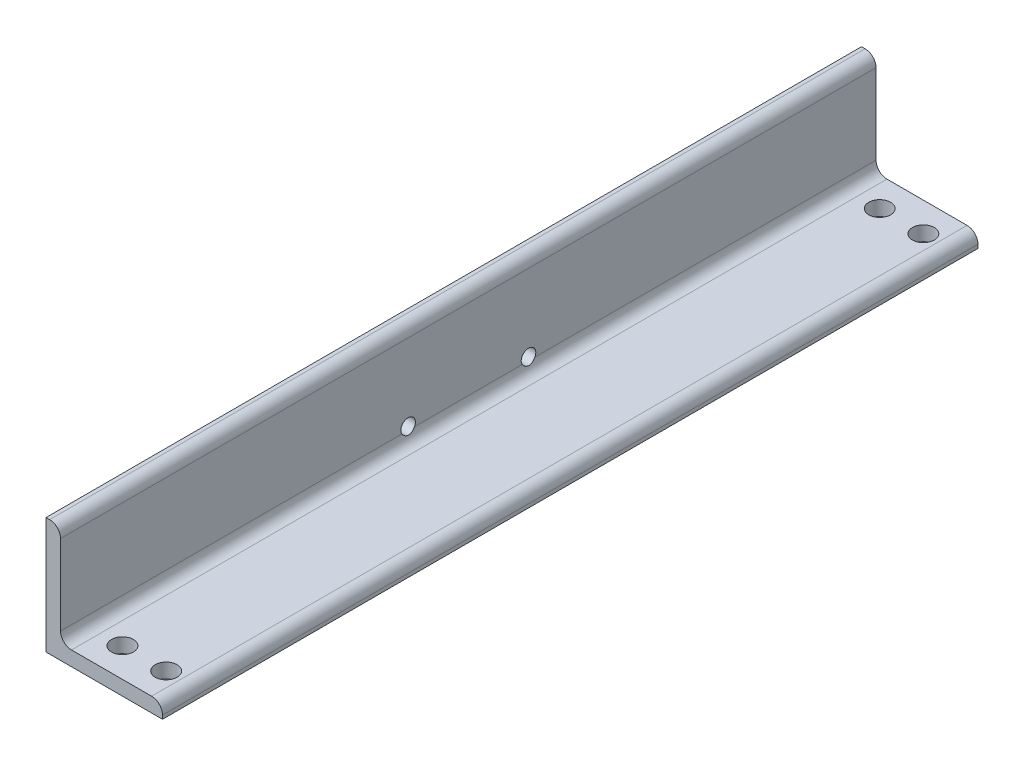
from build123d import *

# Parameters (mm, degrees)
BOSS_EXTRUDE1_DEPTH = 355.6
CUT_EXTRUDE1_REACH  = 14.7
SKETCH3_R           = 9.525
CUT_EXTRUDE2_REACH  = 103.6
SKETCH4_R           = 6.35


with BuildPart() as part:
    # Sketch1 → Boss-Extrude1 (new body, symmetric)
    with BuildSketch(Plane.XY):
        with BuildLine():
            Line((0, 0), (0, 101.6))
            Line((0, 101.6), (3.18008, 101.6))
            ThreePointArc((3.18008, 101.6), (9.911679988, 98.811679988), (12.7, 92.08008))
            Line((12.7, 92.08008), (12.7, 22.225))
            ThreePointArc((12.7, 22.225), (15.489807909, 15.489807909), (22.225, 12.7))
            Line((22.225, 12.7), (92.08008, 12.7))
            ThreePointArc((92.08008, 12.7), (98.811679988, 9.911679988), (101.6, 3.18008))
            Line((101.6, 3.18008), (101.6, 0))
            Line((101.6, 0), (0, 0))
        make_face()
    extrude(amount=BOSS_EXTRUDE1_DEPTH, both=True)

    # Sketch3 → Cut-Extrude1 (cut, up to next)
    with BuildSketch(Plane(origin=(25.4, 12.7, 0), x_dir=(0, 0, -1), z_dir=(0, 1, 0)), mode=Mode.PRIVATE) as cut_extrude1_sk1:
        with Locations((330.2, -15.875)):
            Circle(SKETCH3_R)
    cut_extrude1_tool1 = extrude(cut_extrude1_sk1.sketch, amount=-CUT_EXTRUDE1_REACH, mode=Mode.PRIVATE) & part.part
    add(cut_extrude1_tool1.solids().sort_by_distance((41.275, 12.7, -330.2))[0], mode=Mode.SUBTRACT)
    # Sketch3 → Cut-Extrude1 (cut, up to next)
    with BuildSketch(Plane(origin=(25.4, 12.7, 0), x_dir=(0, 0, -1), z_dir=(0, 1, 0)), mode=Mode.PRIVATE) as cut_extrude1_sk2:
        with Locations((-330.2, -15.875)):
            Circle(SKETCH3_R)
    cut_extrude1_tool2 = extrude(cut_extrude1_sk2.sketch, amount=-CUT_EXTRUDE1_REACH, mode=Mode.PRIVATE) & part.part
    add(cut_extrude1_tool2.solids().sort_by_distance((41.275, 12.7, 330.2))[0], mode=Mode.SUBTRACT)
    # Sketch3 → Cut-Extrude1 (cut, up to next)
    with BuildSketch(Plane(origin=(25.4, 12.7, 0), x_dir=(0, 0, -1), z_dir=(0, 1, 0)), mode=Mode.PRIVATE) as cut_extrude1_sk3:
        with Locations((-330.2, -53.975)):
            Circle(SKETCH3_R)
    cut_extrude1_tool3 = extrude(cut_extrude1_sk3.sketch, amount=-CUT_EXTRUDE1_REACH, mode=Mode.PRIVATE) & part.part
    add(cut_extrude1_tool3.solids().sort_by_distance((79.375, 12.7, 330.2))[0], mode=Mode.SUBTRACT)
    # Sketch3 → Cut-Extrude1 (cut, up to next)
    with BuildSketch(Plane(origin=(25.4, 12.7, 0), x_dir=(0, 0, -1), z_dir=(0, 1, 0)), mode=Mode.PRIVATE) as cut_extrude1_sk4:
        with Locations((330.2, -53.975)):
            Circle(SKETCH3_R)
    cut_extrude1_tool4 = extrude(cut_extrude1_sk4.sketch, amount=-CUT_EXTRUDE1_REACH, mode=Mode.PRIVATE) & part.part
    add(cut_extrude1_tool4.solids().sort_by_distance((79.375, 12.7, -330.2))[0], mode=Mode.SUBTRACT)

    # Sketch4 → Cut-Extrude2 (cut, up to next)
    with BuildSketch(Plane.ZY, mode=Mode.PRIVATE) as cut_extrude2_sk1:
        with Locations((-52.4891, 25.4)):
            Circle(SKETCH4_R)
    cut_extrude2_tool1 = extrude(cut_extrude2_sk1.sketch, amount=-CUT_EXTRUDE2_REACH, mode=Mode.PRIVATE) & part.part
    add(cut_extrude2_tool1.solids().sort_by_distance((0, 25.4, -52.4891))[0], mode=Mode.SUBTRACT)
    # Sketch4 → Cut-Extrude2 (cut, up to next)
    with BuildSketch(Plane.ZY, mode=Mode.PRIVATE) as cut_extrude2_sk2:
        with Locations((52.4891, 25.4)):
            Circle(SKETCH4_R)
    cut_extrude2_tool2 = extrude(cut_extrude2_sk2.sketch, amount=-CUT_EXTRUDE2_REACH, mode=Mode.PRIVATE) & part.part
    add(cut_extrude2_tool2.solids().sort_by_distance((0, 25.4, 52.4891))[0], mode=Mode.SUBTRACT)


solid = part.part
